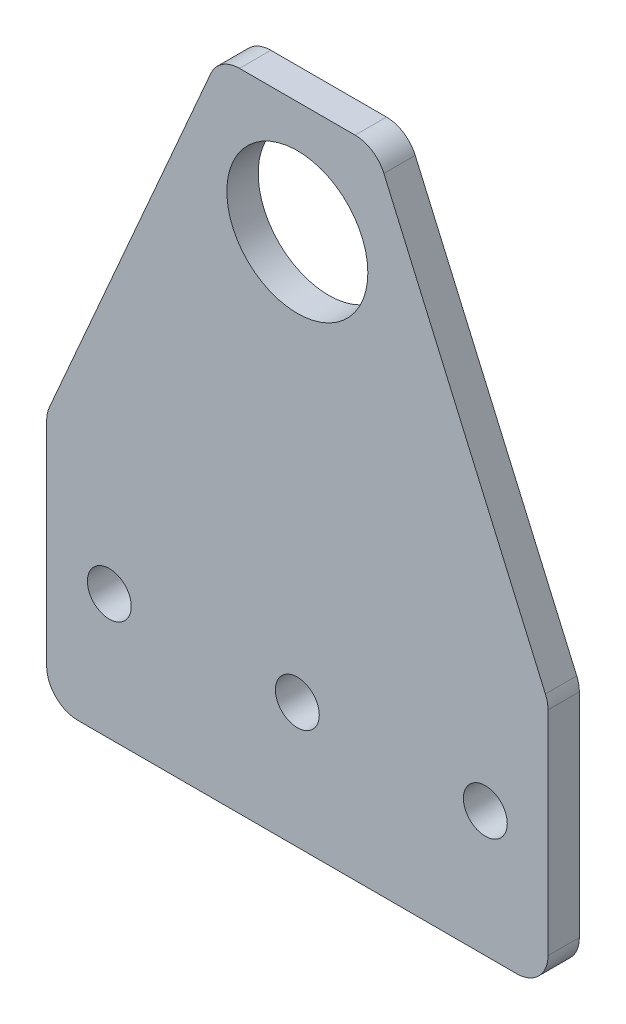
from build123d import *

# Parameters (mm, degrees)
ESQUISSE1_R        = 11.25
ESQUISSE1_R_2      = 3.5
BOSS_EXTRU_1_DEPTH = 5
CONG_1_R           = 5


with BuildPart() as part:
    # Esquisse1 → Boss.-Extru.1 (new body)
    with BuildSketch(Plane.XY):
        Polygon((-40, 0), (40, 0), (40, 40), (12.5, 103), (-12.5, 103), (-40, 40), align=None)
        with Locations((0, 85)):
            Circle(ESQUISSE1_R, mode=Mode.SUBTRACT)
        with Locations((0, 20)):
            Circle(ESQUISSE1_R_2, mode=Mode.SUBTRACT)
        with Locations((30, 20)):
            Circle(ESQUISSE1_R_2, mode=Mode.SUBTRACT)
        with Locations((-30, 20)):
            Circle(ESQUISSE1_R_2, mode=Mode.SUBTRACT)
    extrude(amount=BOSS_EXTRU_1_DEPTH)

    # Congé1
    cong_1_edges = [part.edges().sort_by_distance(p)[0] for p in [
        (-12.5, 103, 2.5),
        (12.5, 103, 2.5),
        (40, 40, 2.5),
        (40, 0, 2.5),
        (-40, 0, 2.5),
        (-40, 40, 2.5),
    ]]
    fillet(cong_1_edges, radius=CONG_1_R)


solid = part.part
